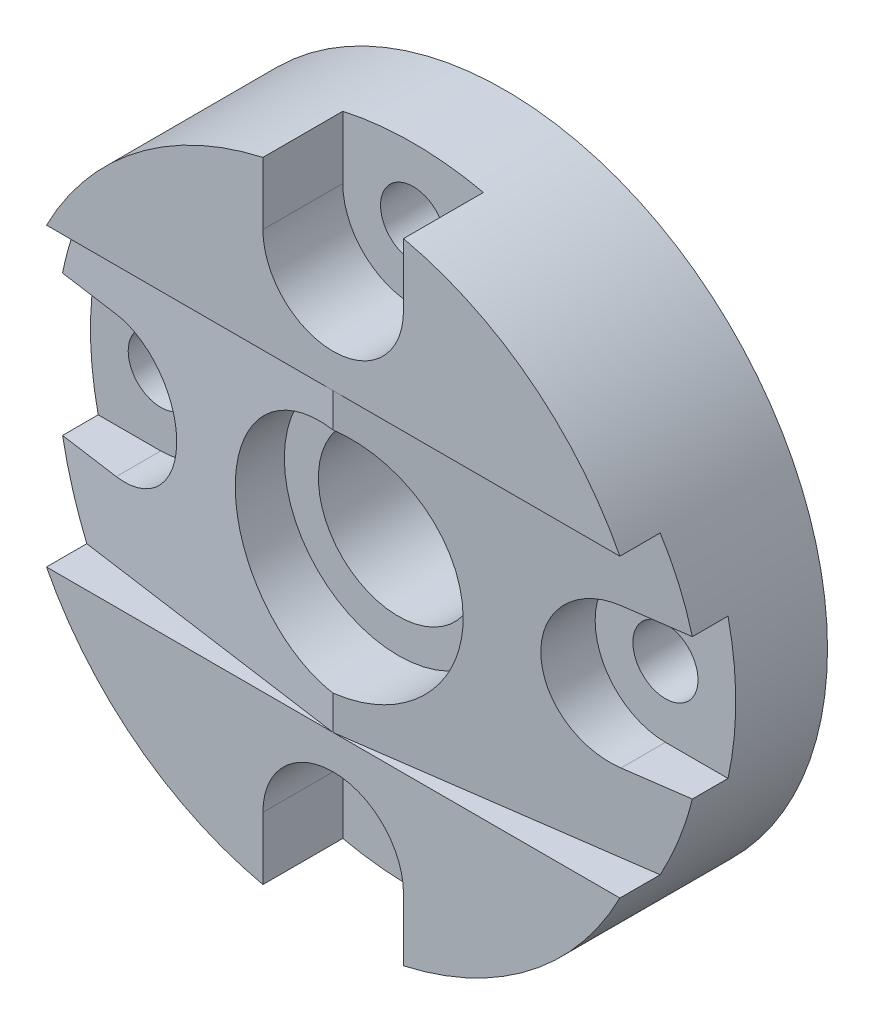
from build123d import *

# Parameters (mm, degrees)
SKETCH1_R          = 55.372
EXTRUDE1_DEPTH     = 29.464
SKETCH4_R          = 13.716
CUT_EXTRUDE1_DEPTH = 29.464
SKETCH5_R          = 19.558
CUT_EXTRUDE2_DEPTH = 11.176
SKETCH6_W          = 66.904134355
SKETCH6_H          = 50.8
CUT_REVOLVE1_ANGLE = 8
CUT_EXTRUDE4_START = 15.748
CUT_EXTRUDE4_DEPTH = 14.716
SKETCH12_R         = 5.588
CUT_EXTRUDE5_DEPTH = 30.464
CIRPATTERN1_COUNT  = 4


with BuildPart() as part:
    # Sketch1 → Extrude1 (new body)
    with BuildSketch(Plane.XY):
        Circle(SKETCH1_R)
    extrude(amount=EXTRUDE1_DEPTH)

    # Sketch4 → Cut-Extrude1 (cut)
    with BuildSketch(Plane.XY.offset(29.464)):
        Circle(SKETCH4_R)
    extrude(amount=-CUT_EXTRUDE1_DEPTH, mode=Mode.SUBTRACT)

    # Sketch5 → Cut-Extrude2 (cut)
    with BuildSketch(Plane.XY.offset(29.464)):
        Circle(SKETCH5_R)
    extrude(amount=-CUT_EXTRUDE2_DEPTH, mode=Mode.SUBTRACT)

    # Sketch6 → Cut-Revolve1 (revolve, cut)
    with BuildSketch(Plane.XY.offset(29.464)):
        with Locations((33.452067178, 0)):
            Rectangle(SKETCH6_W, SKETCH6_H)
    cut_revolve1 = revolve(axis=Axis((0, 25.4, 29.464), (0, 1, 0)), revolution_arc=CUT_REVOLVE1_ANGLE, mode=Mode.SUBTRACT)

    # Mirror1: Cut-Revolve1 across plane
    add(cut_revolve1.mirror(Plane(origin=(0, 0, 0), x_dir=(0, 0, 1), z_dir=(1, 0, 0))), mode=Mode.SUBTRACT)

    # Sketch9 → Cut-Extrude4 (cut, through all)
    with BuildSketch(Plane.XY.offset(CUT_EXTRUDE4_START)):
        with BuildLine():
            Line((-12.065, 43.307), (-12.065, 67.279112083))
            Line((-12.065, 67.279112083), (12.065, 66.235281078))
            Line((12.065, 66.235281078), (12.065, 43.307))
            ThreePointArc((12.065, 43.307), (0, 31.242), (-12.065, 43.307))
        make_face()
    cut_extrude4 = extrude(amount=CUT_EXTRUDE4_DEPTH, mode=Mode.SUBTRACT)

    # Sketch12 → Cut-Extrude5 (cut, through all)
    with BuildSketch(Plane.XY):
        with Locations((0, 43.307)):
            Circle(SKETCH12_R)
    cut_extrude5 = extrude(amount=CUT_EXTRUDE5_DEPTH, mode=Mode.SUBTRACT)

    # CirPattern1: Cut-Extrude4, Cut-Extrude5 ×4 about axis
    cirpattern1_axis = Axis((0, 0, 0), (0, 0, 1))
    for i in range(1, CIRPATTERN1_COUNT):
        add(cut_extrude4.rotate(cirpattern1_axis, i * 360 / CIRPATTERN1_COUNT), mode=Mode.SUBTRACT)
        add(cut_extrude5.rotate(cirpattern1_axis, i * 360 / CIRPATTERN1_COUNT), mode=Mode.SUBTRACT)


solid = part.part
